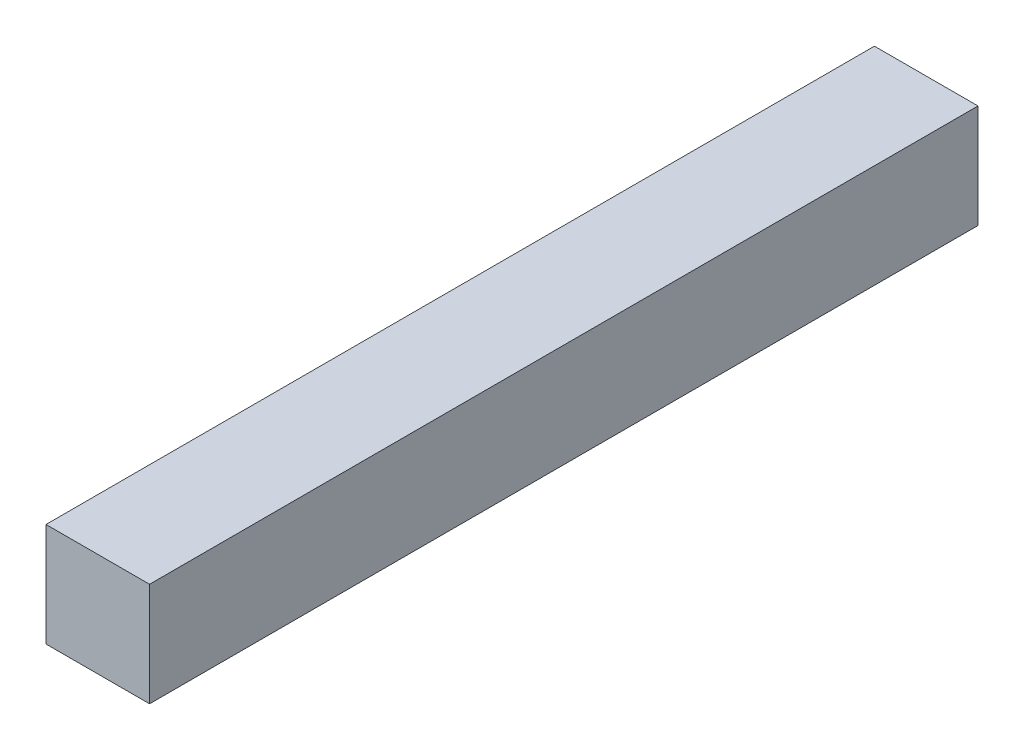
from build123d import *

# Parameters (mm, degrees)
SKETCH1_W           = 10
SKETCH1_H           = 10
BOSS_EXTRUDE1_DEPTH = 80


with BuildPart() as part:
    # Sketch1 → Boss-Extrude1 (new body)
    with BuildSketch(Plane.XY):
        Rectangle(SKETCH1_W, SKETCH1_H)
    extrude(amount=BOSS_EXTRUDE1_DEPTH)


solid = part.part
